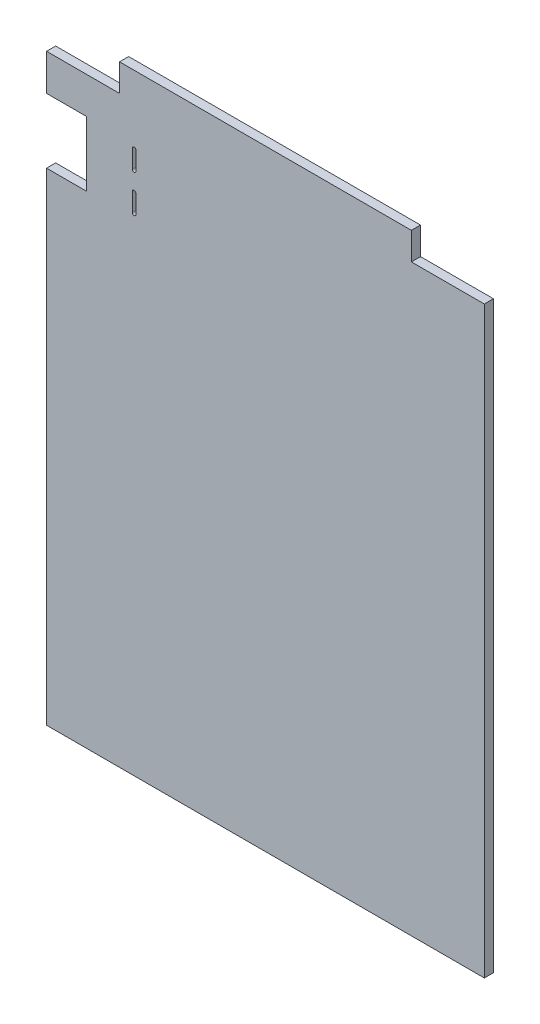
from build123d import *

# Parameters (mm, degrees)
ESQUISSE1_W             = 480
ESQUISSE1_H             = 670
BOSS_EXTRU_1_DEPTH      = 10
ESQUISSE2_W             = 80
ESQUISSE2_H             = 30
ENL_V_MAT_EXTRU_1_DEPTH = 11
ESQUISSE3_W             = 44
ESQUISSE3_H             = 71
ENL_V_MAT_EXTRU_2_DEPTH = 11


with BuildPart() as part:
    # Esquisse1 → Boss.-Extru.1 (new body)
    with BuildSketch(Plane.XY):
        with Locations((-50, 0)):
            Rectangle(ESQUISSE1_W, ESQUISSE1_H)
    extrude(amount=BOSS_EXTRU_1_DEPTH)

    # Esquisse2 → Enlèv. mat.-Extru.1 (cut, through all)
    with BuildSketch(Plane(origin=(0, 0, 0), x_dir=(-1, 0, 0), z_dir=(0, 0, -1))):
        with Locations((-150, 320)):
            Rectangle(ESQUISSE2_W, ESQUISSE2_H)
        with Locations((250, 320)):
            Rectangle(ESQUISSE2_W, ESQUISSE2_H)
    extrude(amount=-ENL_V_MAT_EXTRU_1_DEPTH, mode=Mode.SUBTRACT)

    # Esquisse3 → Enlèv. mat.-Extru.2 (cut, through all)
    with BuildSketch(Plane(origin=(0, 0, 0), x_dir=(-1, 0, 0), z_dir=(0, 0, -1))):
        with BuildLine():
            Line((192, 260), (192, 240))
            ThreePointArc((192, 240), (194, 238), (196, 240))
            Line((196, 240), (196, 260))
            ThreePointArc((196, 260), (194, 262), (192, 260))
        make_face()
        with BuildLine():
            Line((192, 219), (192, 199))
            ThreePointArc((192, 199), (194, 197), (196, 199))
            Line((196, 199), (196, 219))
            ThreePointArc((196, 219), (194, 221), (192, 219))
        make_face()
        with Locations((268, 229.5)):
            Rectangle(ESQUISSE3_W, ESQUISSE3_H)
    extrude(amount=-ENL_V_MAT_EXTRU_2_DEPTH, mode=Mode.SUBTRACT)


solid = part.part
